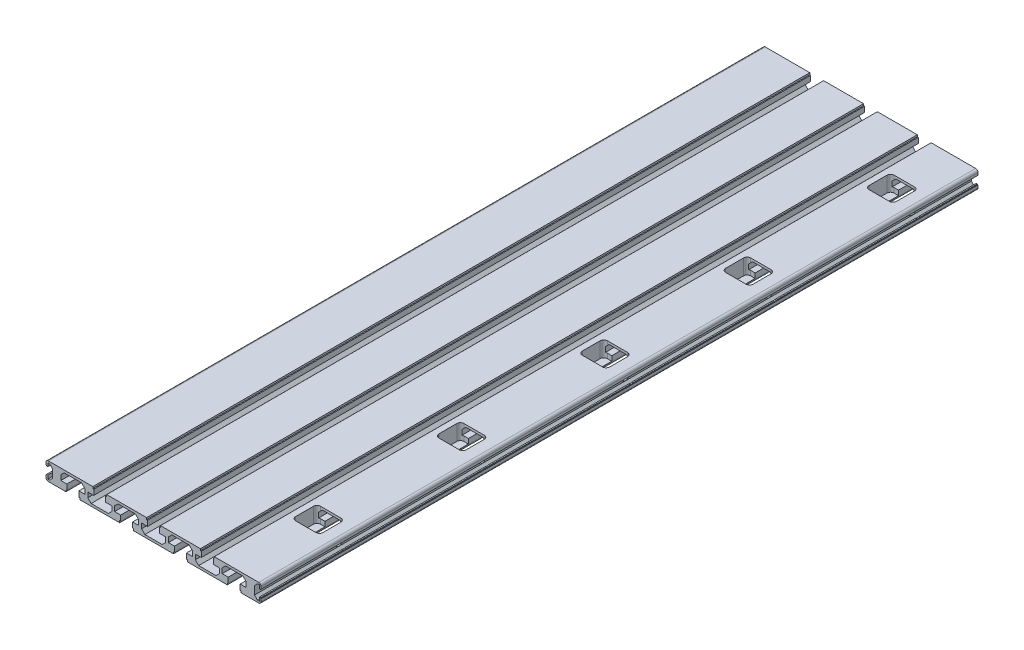
from build123d import *

# Parameters (mm, degrees)
EXTRUDE_1_DEPTH        = 600
CUT_EXTRUDE_1_DEPTH    = 13
SKETCH_5_R             = 3.25
CUT_EXTRUDE_2_DEPTH    = 13.45
PATTERN_LINEAR_1_COUNT = 5
PATTERN_LINEAR_1_PITCH = 120


with BuildPart() as part:
    # Эскиз1 → Бобышка-Вытянуть1 (new body)
    with BuildSketch(Plane.XY):
        with BuildLine():
            Line((-87.448760965, -5.103459789), (-88.898760965, -5.103459789))
            Line((-88.898760965, -5.103459789), (-88.898760965, -2.103459789))
            Line((-88.898760965, -2.103459789), (-89.898760965, -2.103459789))
            Line((-89.898760965, -2.103459789), (-89.898760965, -2.603459789))
            Line((-89.898760965, -2.603459789), (-90.398760965, -2.603459789))
            Line((-90.398760965, -2.603459789), (-90.398760965, -4.603459781))
            ThreePointArc((-90.398760965, -4.603459781), (-89.812974525, -6.017673349), (-88.398760957, -6.603459789))
            Line((-88.398760957, -6.603459789), (-73.698760965, -6.603459789))
            Line((-73.698760965, -6.603459789), (-73.698760965, -5.103459789))
            Line((-73.698760965, -5.103459789), (-72.898760965, -5.103459789))
            Line((-72.898760965, -5.103459789), (-72.898760965, -0.603459789))
            Line((-72.898760965, -0.603459789), (-77.948760965, -0.603459789))
            Line((-77.948760965, -0.603459789), (-77.948760965, 3.596540211))
            Line((-77.948760965, 3.596540211), (-75.148760965, 6.396540211))
            Line((-75.148760965, 6.396540211), (-60.648760965, 6.396540211))
            Line((-60.648760965, 6.396540211), (-57.848760965, 3.596540211))
            Line((-57.848760965, 3.596540211), (-57.848760965, -0.603459789))
            Line((-57.848760965, -0.603459789), (-62.898760965, -0.603459789))
            Line((-62.898760965, -0.603459789), (-62.898760965, -5.103459789))
            Line((-62.898760965, -5.103459789), (-62.098760965, -5.103459789))
            Line((-62.098760965, -5.103459789), (-62.098760965, -6.603459789))
            Line((-62.098760965, -6.603459789), (-28.698760965, -6.603459789))
            Line((-28.698760965, -6.603459789), (-28.698760965, -5.103459789))
            Line((-28.698760965, -5.103459789), (-27.898760965, -5.103459789))
            Line((-27.898760965, -5.103459789), (-27.898760965, -0.603459789))
            Line((-27.898760965, -0.603459789), (-32.948760965, -0.603459789))
            Line((-32.948760965, -0.603459789), (-32.948760965, 3.596540211))
            Line((-32.948760965, 3.596540211), (-30.148760965, 6.396540211))
            Line((-30.148760965, 6.396540211), (-15.648760965, 6.396540211))
            Line((-15.648760965, 6.396540211), (-12.848760965, 3.596540211))
            Line((-12.848760965, 3.596540211), (-12.848760965, -0.603459789))
            Line((-12.848760965, -0.603459789), (-17.898760965, -0.603459789))
            Line((-17.898760965, -0.603459789), (-17.898760965, -5.103459789))
            Line((-17.898760965, -5.103459789), (-17.098760965, -5.103459789))
            Line((-17.098760965, -5.103459789), (-17.098760965, -6.603459789))
            Line((-17.098760965, -6.603459789), (16.301239035, -6.603459789))
            Line((16.301239035, -6.603459789), (16.301239035, -5.103459789))
            Line((16.301239035, -5.103459789), (17.101239035, -5.103459789))
            Line((17.101239035, -5.103459789), (17.101239035, -0.603459789))
            Line((17.101239035, -0.603459789), (12.051239035, -0.603459789))
            Line((12.051239035, -0.603459789), (12.051239035, 3.596540211))
            Line((12.051239035, 3.596540211), (14.851239035, 6.396540211))
            Line((14.851239035, 6.396540211), (29.351239035, 6.396540211))
            Line((29.351239035, 6.396540211), (32.151239035, 3.596540211))
            Line((32.151239035, 3.596540211), (32.151239035, -0.603459789))
            Line((32.151239035, -0.603459789), (27.101239035, -0.603459789))
            Line((27.101239035, -0.603459789), (27.101239035, -5.103459789))
            Line((27.101239035, -5.103459789), (27.901239035, -5.103459789))
            Line((27.901239035, -5.103459789), (27.901239035, -6.603459789))
            Line((27.901239035, -6.603459789), (61.301239035, -6.603459789))
            Line((61.301239035, -6.603459789), (61.301239035, -5.103459789))
            Line((61.301239035, -5.103459789), (62.101239035, -5.103459789))
            Line((62.101239035, -5.103459789), (62.101239035, -0.603459789))
            Line((62.101239035, -0.603459789), (57.051239035, -0.603459789))
            Line((57.051239035, -0.603459789), (57.051239035, 3.596540211))
            Line((57.051239035, 3.596540211), (59.851239035, 6.396540211))
            Line((59.851239035, 6.396540211), (74.351239035, 6.396540211))
            Line((74.351239035, 6.396540211), (77.151239035, 3.596540211))
            Line((77.151239035, 3.596540211), (77.151239035, -0.603459789))
            Line((77.151239035, -0.603459789), (72.101239035, -0.603459789))
            Line((72.101239035, -0.603459789), (72.101239035, -5.103459789))
            Line((72.101239035, -5.103459789), (72.901239035, -5.103459789))
            Line((72.901239035, -5.103459789), (72.901239035, -6.603459789))
            Line((72.901239035, -6.603459789), (87.601239027, -6.603459789))
            ThreePointArc((87.601239027, -6.603459789), (89.015452595, -6.017673349), (89.601239035, -4.603459781))
            Line((89.601239035, -4.603459781), (89.601239035, -2.603459789))
            Line((89.601239035, -2.603459789), (89.101239035, -2.603459789))
            Line((89.101239035, -2.603459789), (89.101239035, -2.103459789))
            Line((89.101239035, -2.103459789), (88.101239035, -2.103459789))
            Line((88.101239035, -2.103459789), (88.101239035, -5.103459789))
            Line((88.101239035, -5.103459789), (86.651239035, -5.103459789))
            Line((86.651239035, -5.103459789), (84.101239035, -2.553459789))
            Line((84.101239035, -2.553459789), (84.101239035, 4.346540211))
            Line((84.101239035, 4.346540211), (86.651239035, 6.896540211))
            Line((86.651239035, 6.896540211), (88.101239035, 6.896540211))
            Line((88.101239035, 6.896540211), (88.101239035, 3.896540211))
            Line((88.101239035, 3.896540211), (89.101239035, 3.896540211))
            Line((89.101239035, 3.896540211), (89.101239035, 4.396540211))
            Line((89.101239035, 4.396540211), (89.601239035, 4.396540211))
            Line((89.601239035, 4.396540211), (89.601239035, 6.396540203))
            ThreePointArc((89.601239035, 6.396540203), (89.015452595, 7.810753771), (87.601239027, 8.396540211))
            Line((87.601239027, 8.396540211), (50.401239035, 8.396540211))
            Line((50.401239035, 8.396540211), (50.401239035, 6.896540211))
            Line((50.401239035, 6.896540211), (49.601239036, 6.896540211))
            Line((49.601239036, 6.896540211), (49.601239036, 2.396540208))
            Line((49.601239036, 2.396540208), (54.651239036, 2.396540208))
            Line((54.651239036, 2.396540208), (54.651239036, -1.803459792))
            Line((54.651239036, -1.803459792), (51.851239036, -4.603459792))
            Line((51.851239036, -4.603459792), (37.351239036, -4.603459792))
            Line((37.351239036, -4.603459792), (34.551239036, -1.803459792))
            Line((34.551239036, -1.803459792), (34.551239036, 2.396540208))
            Line((34.551239036, 2.396540208), (39.601239036, 2.396540208))
            Line((39.601239036, 2.396540208), (39.601239036, 6.896540211))
            Line((39.601239036, 6.896540211), (38.801239035, 6.896540211))
            Line((38.801239035, 6.896540211), (38.801239035, 8.396540211))
            Line((38.801239035, 8.396540211), (5.401239035, 8.396540211))
            Line((5.401239035, 8.396540211), (5.401239035, 6.896540211))
            Line((5.401239035, 6.896540211), (4.601239036, 6.896540211))
            Line((4.601239036, 6.896540211), (4.601239036, 2.396540208))
            Line((4.601239036, 2.396540208), (9.651239036, 2.396540208))
            Line((9.651239036, 2.396540208), (9.651239036, -1.803459792))
            Line((9.651239036, -1.803459792), (6.851239036, -4.603459792))
            Line((6.851239036, -4.603459792), (-7.648760964, -4.603459792))
            Line((-7.648760964, -4.603459792), (-10.448760964, -1.803459792))
            Line((-10.448760964, -1.803459792), (-10.448760964, 2.396540208))
            Line((-10.448760964, 2.396540208), (-5.398760964, 2.396540208))
            Line((-5.398760964, 2.396540208), (-5.398760964, 6.896540211))
            Line((-5.398760964, 6.896540211), (-6.198760965, 6.896540211))
            Line((-6.198760965, 6.896540211), (-6.198760965, 8.396540211))
            Line((-6.198760965, 8.396540211), (-39.598760965, 8.396540211))
            Line((-39.598760965, 8.396540211), (-39.598760965, 6.896540211))
            Line((-39.598760965, 6.896540211), (-40.398760964, 6.896540211))
            Line((-40.398760964, 6.896540211), (-40.398760964, 2.396540208))
            Line((-40.398760964, 2.396540208), (-35.348760964, 2.396540208))
            Line((-35.348760964, 2.396540208), (-35.348760964, -1.803459792))
            Line((-35.348760964, -1.803459792), (-38.148760964, -4.603459792))
            Line((-38.148760964, -4.603459792), (-52.648760964, -4.603459792))
            Line((-52.648760964, -4.603459792), (-55.448760964, -1.803459792))
            Line((-55.448760964, -1.803459792), (-55.448760964, 2.396540208))
            Line((-55.448760964, 2.396540208), (-50.398760964, 2.396540208))
            Line((-50.398760964, 2.396540208), (-50.398760964, 6.896540211))
            Line((-50.398760964, 6.896540211), (-51.198760965, 6.896540211))
            Line((-51.198760965, 6.896540211), (-51.198760965, 8.396540211))
            Line((-51.198760965, 8.396540211), (-88.398760957, 8.396540211))
            ThreePointArc((-88.398760957, 8.396540211), (-89.812974525, 7.810753771), (-90.398760965, 6.396540202))
            Line((-90.398760965, 6.396540202), (-90.398760965, 4.396540211))
            Line((-90.398760965, 4.396540211), (-89.898760965, 4.396540211))
            Line((-89.898760965, 4.396540211), (-89.898760965, 3.896540211))
            Line((-89.898760965, 3.896540211), (-88.898760965, 3.896540211))
            Line((-88.898760965, 3.896540211), (-88.898760965, 6.896540211))
            Line((-88.898760965, 6.896540211), (-87.448760965, 6.896540211))
            Line((-87.448760965, 6.896540211), (-84.898760965, 4.346540211))
            Line((-84.898760965, 4.346540211), (-84.898760965, -2.553459789))
            Line((-84.898760965, -2.553459789), (-87.448760965, -5.103459789))
        make_face()
    extrude(amount=EXTRUDE_1_DEPTH)


with BuildPart() as part_1:
    # Move Body 1: moved
    add(part.part.moved(Location((0, 0, -600))))

    # Эскиз4 → Вырез-Вытянуть1 (cut)
    with BuildSketch(Plane(origin=(0, 8.396540211, 0), x_dir=(1, 0, 0), z_dir=(0, 1, 0))):
        with BuildLine():
            Line((75.401239035, 81), (58.401239035, 81))
            ThreePointArc((58.401239035, 81), (56.279918691, 80.121320344), (55.401239035, 78))
            Line((55.401239035, 78), (55.401239035, 63))
            ThreePointArc((55.401239035, 63), (56.279918691, 60.878679656), (58.401239035, 60))
            Line((58.401239035, 60), (75.401239035, 60))
            ThreePointArc((75.401239035, 60), (77.522559378, 60.878679656), (78.401239035, 63))
            Line((78.401239035, 63), (78.401239035, 78))
            ThreePointArc((78.401239035, 78), (77.522559378, 80.121320344), (75.401239035, 81))
        make_face()
    cut_extrude_1 = extrude(amount=-CUT_EXTRUDE_1_DEPTH, mode=Mode.SUBTRACT)

    # Эскиз5 → Вырез-Вытянуть2 (cut, through all)
    with BuildSketch(Plane.ZY.offset(-77.151239035)):
        with Locations(Location((-70.5, 0.896540211, 0), (0, 0, 270))):  # turned: the seam where the file's is
            Circle(SKETCH_5_R)
    cut_extrude_2 = extrude(amount=-CUT_EXTRUDE_2_DEPTH, mode=Mode.SUBTRACT)

    # Линейный массив1: Вырез-Вытянуть1, Вырез-Вытянуть2 ×5
    with Locations(*[(0, 0, -i * PATTERN_LINEAR_1_PITCH) for i in range(1, PATTERN_LINEAR_1_COUNT)]):
        add(cut_extrude_1, mode=Mode.SUBTRACT)
        add(cut_extrude_2, mode=Mode.SUBTRACT)


solid = part_1.part
